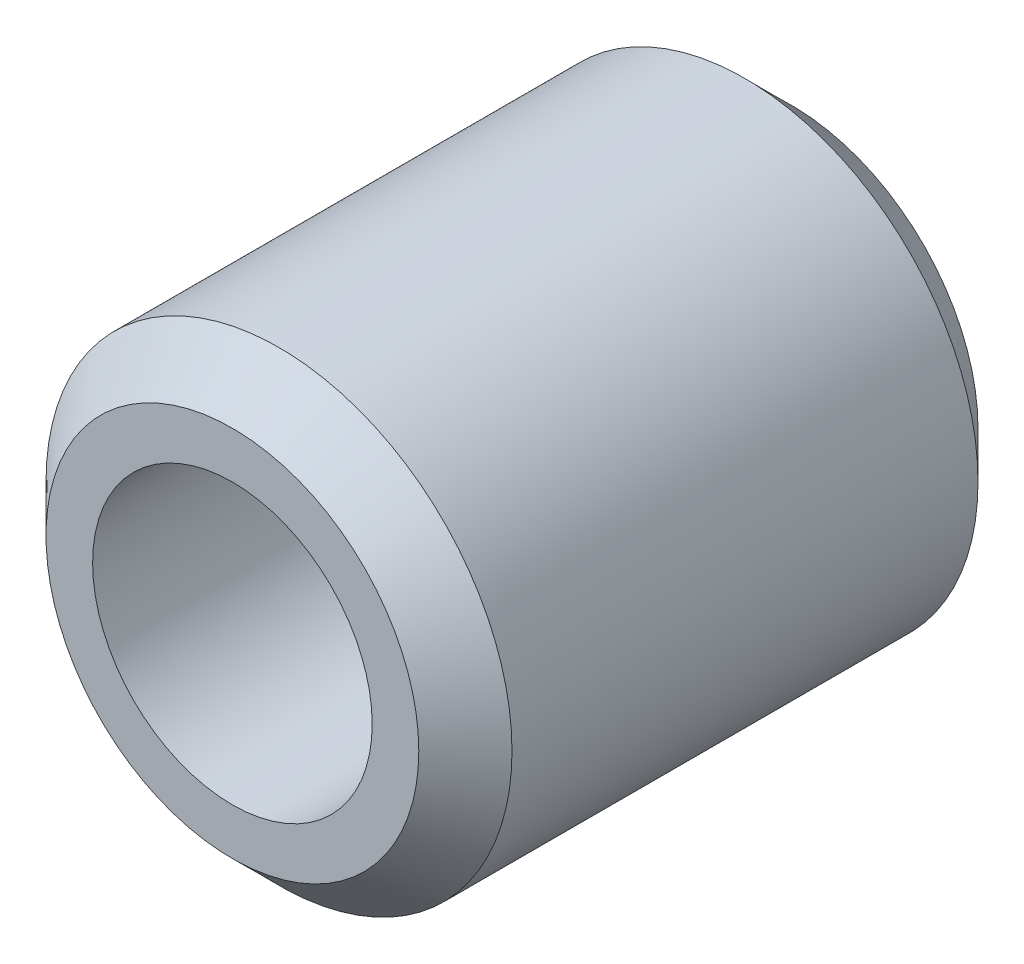
from build123d import *

# Parameters (mm, degrees)
SKETCH1_R           = 7.9375
BOSS_EXTRUDE1_DEPTH = 19.05
SKETCH2_R           = 4.7625
CUT_EXTRUDE1_DEPTH  = 12.7
CHAMFER1_SIZE       = 1.5875


with BuildPart() as part:
    # Sketch1 → Boss-Extrude1 (new body)
    with BuildSketch(Plane.XY):
        Circle(SKETCH1_R)
    extrude(amount=BOSS_EXTRUDE1_DEPTH)

    # Sketch2 → Cut-Extrude1 (cut)
    with BuildSketch(Plane.XY.offset(19.05)):
        Circle(SKETCH2_R)
    extrude(amount=-CUT_EXTRUDE1_DEPTH, mode=Mode.SUBTRACT)

    # Chamfer1
    chamfer1_edges = [part.edges().sort_by_distance(p)[0] for p in [
        (-7.9375, 0, 0),
        (-7.9375, 0, 19.05),
    ]]
    chamfer(chamfer1_edges, length=CHAMFER1_SIZE)


solid = part.part
